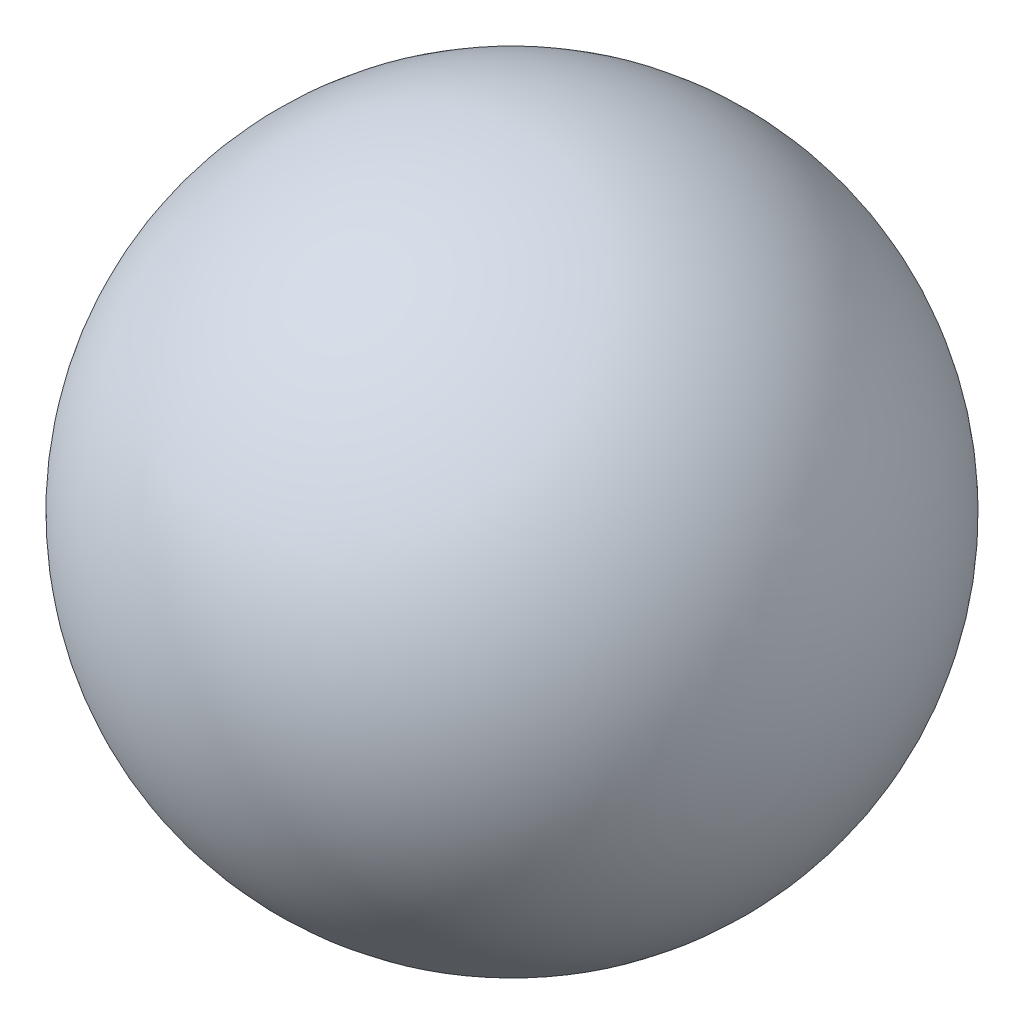
from build123d import *

# Parameters (mm, degrees)
F_1_4_20_TAPPED_HOLE1_D     = 5.1054
F_1_4_20_TAPPED_HOLE1_DEPTH = 6.35
F_1_4_20_TAPPED_HOLE1_TIP   = 1.533816902


with BuildPart() as part:
    # Sketch1 → Revolve1 (revolve)
    with BuildSketch(Plane.XY):
        with BuildLine():
            Line((0, 12.7), (0, -12.7))
            ThreePointArc((0, -12.7), (-12.7, 0), (0, 12.7))
        make_face()
    revolve(axis=Axis((0, 12.7, 0), (0, -1, 0)))

    # 1/4-20 Tapped Hole1
    with Locations(Plane(origin=(0, -12.7, 0), x_dir=(-1, 0, 0), z_dir=(0, -1, 0))):
        with Locations((0, 0)):
            Hole(F_1_4_20_TAPPED_HOLE1_D / 2, depth=F_1_4_20_TAPPED_HOLE1_DEPTH)
            with Locations((0, 0, -(F_1_4_20_TAPPED_HOLE1_DEPTH + F_1_4_20_TAPPED_HOLE1_TIP / 2))):  # 118° drill point
                Cone(0, F_1_4_20_TAPPED_HOLE1_D / 2, F_1_4_20_TAPPED_HOLE1_TIP, mode=Mode.SUBTRACT)


solid = part.part
